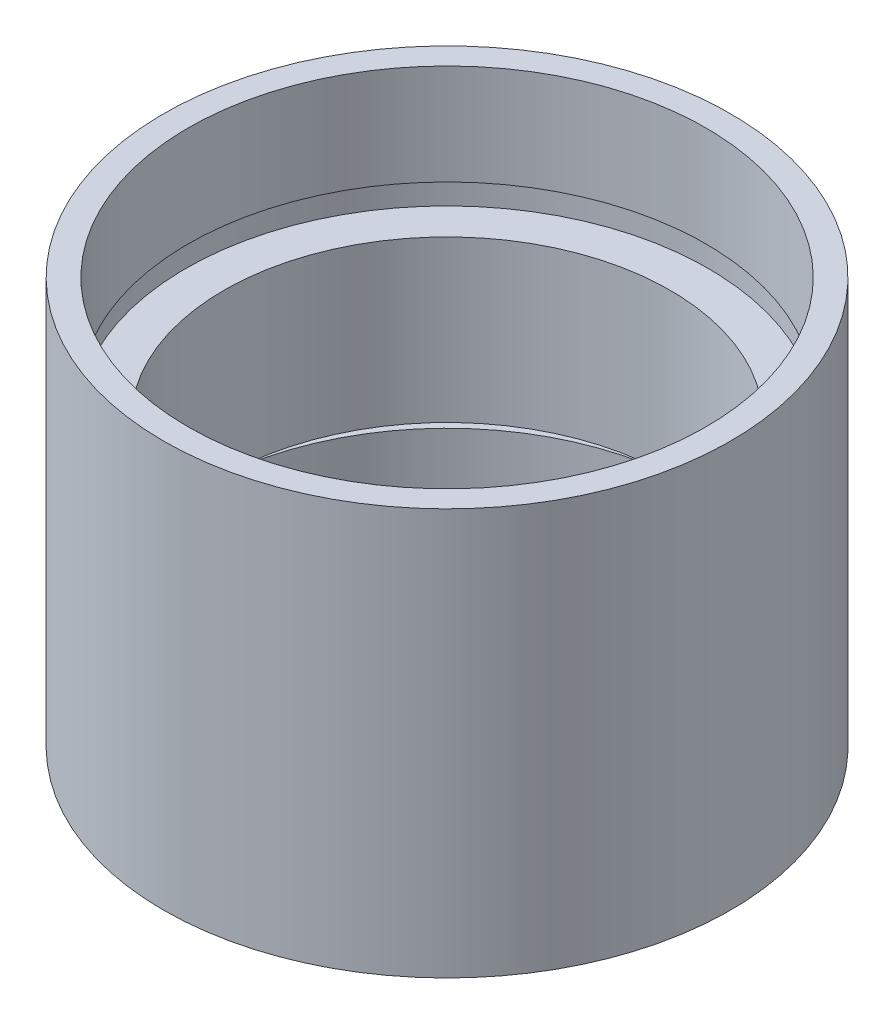
from build123d import *


with BuildPart() as part:
    # 草图1 → 旋转1 (revolve)
    with BuildSketch(Plane.XY, mode=Mode.PRIVATE) as revolve_1_sk:
        Polygon((11.1, 0), (11.1, 4.5), (11.7, 4.5), (11.7, 5.5), (10, 5.5), (10, 12.7), (11.7, 12.7), (11.7, 13.7), (11.6, 13.7), (11.6, 18.2), (12.7, 18.2), (12.7, 0), align=None)
    revolve(revolve_1_sk.sketch.rotate(Axis((0, 161.376166943, 0), (0, -1, 0)), 90), axis=Axis((0, 161.376166943, 0), (0, -1, 0)))  # turned: the seam where the file's is


solid = part.part
